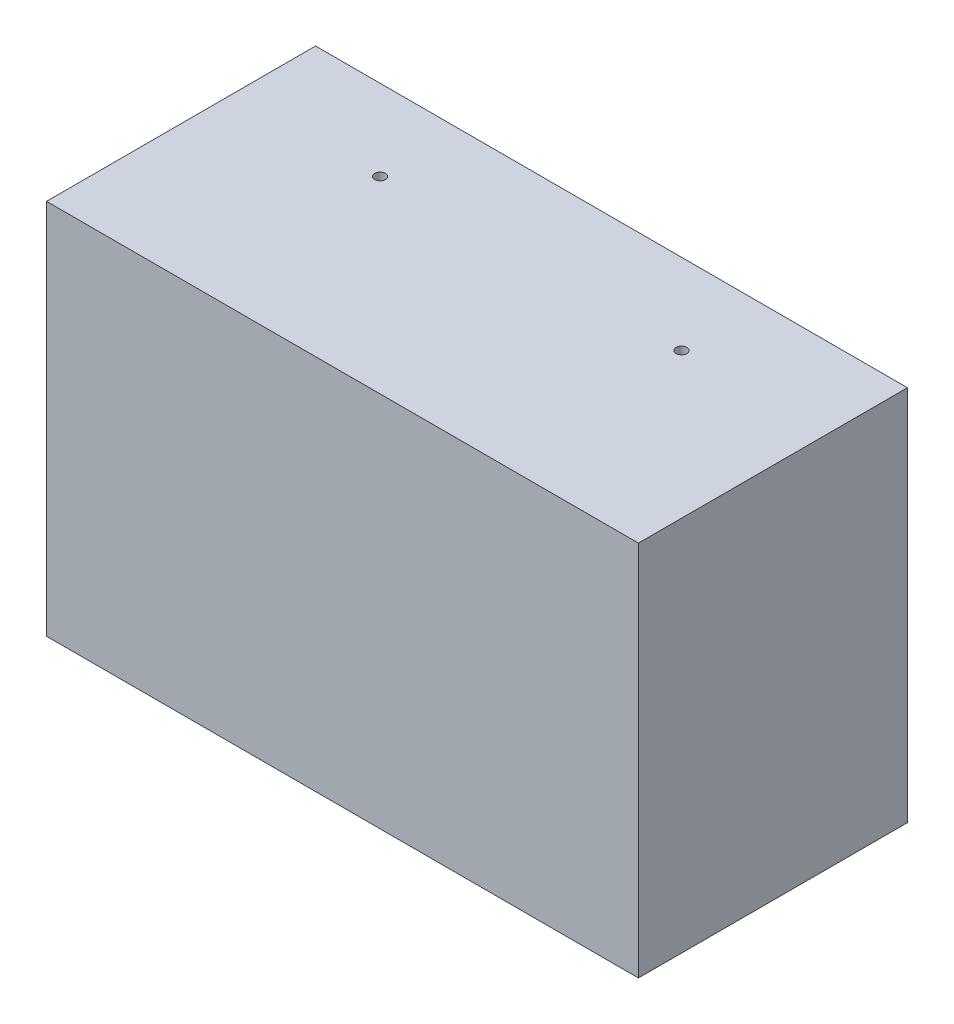
from build123d import *

# Parameters (mm, degrees)
SKETCH_1_W               = 110
SKETCH_1_H               = 70
EXTRUDE_1_DEPTH          = 50
SKETCH_3_W               = 100
SKETCH_3_H               = 60
CUT_EXTRUDE_1_DEPTH      = 35
SKETCH_4_R               = 1
CUT_EXTRUDE_2_DEPTH      = 40
CUT_EXTRUDE_2_DEPTH_BACK = 40


with BuildPart() as part:
    # 草圖1 → 填料-伸長1 (new body)
    with BuildSketch(Plane.XY):
        Rectangle(SKETCH_1_W, SKETCH_1_H)
    extrude(amount=EXTRUDE_1_DEPTH)

    # 草圖3 → 除料-伸長1 (cut)
    with BuildSketch(Plane.XY):
        Rectangle(SKETCH_3_W, SKETCH_3_H)
    extrude(amount=CUT_EXTRUDE_1_DEPTH, mode=Mode.SUBTRACT)

    # 草圖4 → 除料-伸長2 (cut, two sides)
    with BuildSketch(Plane(origin=(0, 0, 0), x_dir=(1, 0, 0), z_dir=(0, 1, 0))) as cut_extrude_2_sk:
        with Locations((28, -15)):
            Circle(SKETCH_4_R)
        with Locations((-28, -15)):
            Circle(SKETCH_4_R)
    extrude(amount=CUT_EXTRUDE_2_DEPTH, mode=Mode.SUBTRACT)
    extrude(cut_extrude_2_sk.sketch, amount=-CUT_EXTRUDE_2_DEPTH_BACK, mode=Mode.SUBTRACT)


solid = part.part
